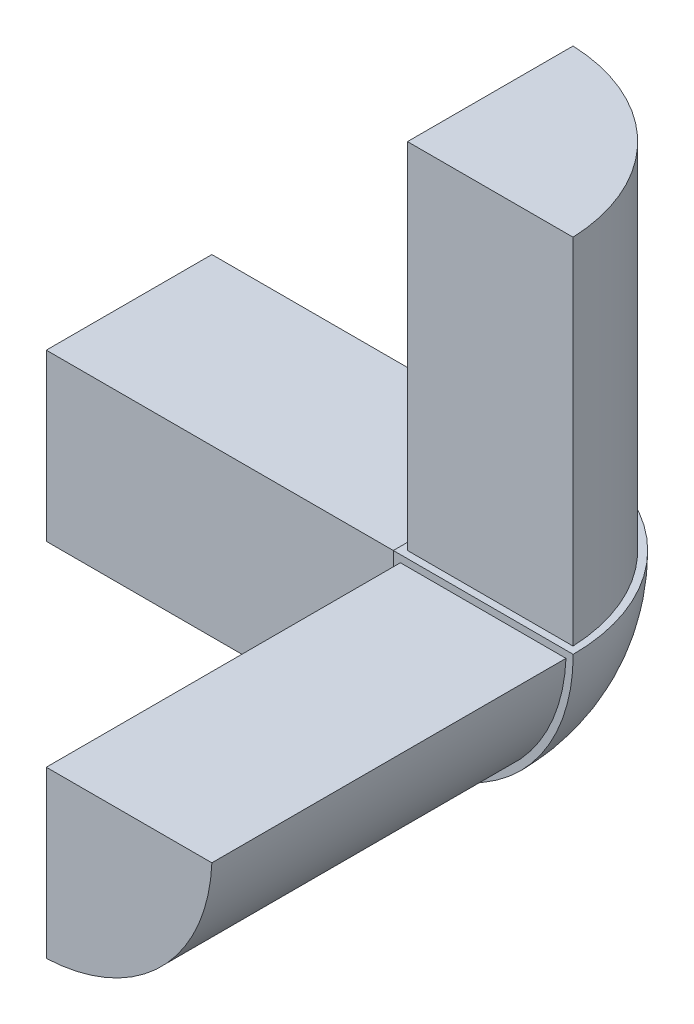
from build123d import *

# Parameters (mm, degrees)
SALIENTE_EXTRUIR1_DEPTH = 50
SALIENTE_EXTRUIR2_DEPTH = 50
SALIENTE_EXTRUIR3_DEPTH = 50
CORTAR_EXTRUIR1_DEPTH   = 30
CROQUIS8_W              = 25.4
CROQUIS8_H              = 25.4
CORTAR_EXTRUIR5_DEPTH   = 50
CROQUIS9_W              = 25.4
CROQUIS9_H              = 25.4
CORTAR_EXTRUIR6_DEPTH   = 50
CORTAR_EXTRUIR7_DEPTH   = 50
CORTAR_EXTRUIR8_DEPTH   = 50
CORTAR_EXTRUIR9_DEPTH   = 50


with BuildPart() as part:
    # Croquis1 → Revolución1 (revolve)
    with BuildSketch(Plane.XY):
        with BuildLine():
            Line((0, 25.4), (0, -25.4))
            ThreePointArc((0, -25.4), (25.4, 0), (0, 25.4))
        make_face()
    revolve(axis=Axis((0, 32.899125747, 0), (0, -1, 0)))

    # Croquis2 → Saliente-Extruir1 (add)
    with BuildSketch(Plane(origin=(0, 0, 0), x_dir=(1, 0, 0), z_dir=(0, 1, 0))):
        with BuildLine():
            Line((0, 25.4), (0, 0))
            Line((0, 0), (25.4, 0))
            ThreePointArc((25.4, 0), (17.960512242, 17.960512242), (0, 25.4))
        make_face()
    extrude(amount=SALIENTE_EXTRUIR1_DEPTH)

    # Croquis3 → Saliente-Extruir2 (add)
    with BuildSketch(Plane.XY):
        with BuildLine():
            Line((0, 0), (25.4, 0))
            ThreePointArc((25.4, 0), (17.960512242, -17.960512242), (0, -25.4))
            Line((0, -25.4), (0, 0))
        make_face()
    extrude(amount=SALIENTE_EXTRUIR2_DEPTH)

    # Croquis4 → Saliente-Extruir3 (add)
    with BuildSketch(Plane(origin=(0, 0, 0), x_dir=(0, 0, -1), z_dir=(1, 0, 0))):
        with BuildLine():
            Line((25.4, 0), (0, 0))
            Line((0, 0), (0, -25.4))
            ThreePointArc((0, -25.4), (17.960512242, -17.960512242), (25.4, 0))
        make_face()
    extrude(amount=-SALIENTE_EXTRUIR3_DEPTH)

    # Croquis5 → Cortar-Extruir1 (cut, symmetric)
    with BuildSketch(Plane.XY):
        with BuildLine():
            Line((0, 25.4), (0, 0))
            Line((0, 0), (-25.4, 0))
            ThreePointArc((-25.4, 0), (-17.960512242, 17.960512242), (0, 25.4))
        make_face()
    extrude(amount=CORTAR_EXTRUIR1_DEPTH, both=True, mode=Mode.SUBTRACT)

    # Croquis8 → Cortar-Extruir5 (cut)
    with BuildSketch(Plane(origin=(0, 0, 0), x_dir=(0, 0, -1), z_dir=(1, 0, 0))):
        with Locations((-12.7, 12.7)):
            Rectangle(CROQUIS8_W, CROQUIS8_H)
    extrude(amount=CORTAR_EXTRUIR5_DEPTH, mode=Mode.SUBTRACT)

    # Croquis9 → Cortar-Extruir6 (cut)
    with BuildSketch(Plane(origin=(0, 0, 0), x_dir=(1, 0, 0), z_dir=(0, 1, 0))):
        with Locations((-12.7, -12.7)):
            Rectangle(CROQUIS9_W, CROQUIS9_H)
    extrude(amount=-CORTAR_EXTRUIR6_DEPTH, mode=Mode.SUBTRACT)

    # Croquis11 → Cortar-Extruir7 (cut)
    with BuildSketch(Plane.ZY.offset(50)):
        with BuildLine():
            Line((0, -25.4), (0, 0))
            Line((0, 0), (-25.4, 0))
            ThreePointArc((-25.4, 0), (-17.960512242, -17.960512242), (0, -25.4))
        make_face()
        with BuildLine():
            Line((-1, -24.379499585), (-1, -1))
            Line((-1, -1), (-24.379499585, -1))
            ThreePointArc((-24.379499585, -1), (-17.253405461, -17.253405461), (-1, -24.379499585))
        make_face(mode=Mode.SUBTRACT)
    extrude(amount=-CORTAR_EXTRUIR7_DEPTH, mode=Mode.SUBTRACT)

    # Croquis12 → Cortar-Extruir8 (cut)
    with BuildSketch(Plane(origin=(0, 50, 0), x_dir=(1, 0, 0), z_dir=(0, 1, 0))):
        with BuildLine():
            Line((0, 25.4), (0, 0))
            Line((0, 0), (25.4, 0))
            ThreePointArc((25.4, 0), (17.960512242, 17.960512242), (0, 25.4))
        make_face()
        with BuildLine():
            Line((1, 24.379499585), (1, 1))
            Line((1, 1), (24.379499585, 1))
            ThreePointArc((24.379499585, 1), (17.253405461, 17.253405461), (1, 24.379499585))
        make_face(mode=Mode.SUBTRACT)
    extrude(amount=-CORTAR_EXTRUIR8_DEPTH, mode=Mode.SUBTRACT)

    # Croquis13 → Cortar-Extruir9 (cut)
    with BuildSketch(Plane.XY.offset(50)):
        with BuildLine():
            Line((0, 0), (0, -25.4))
            ThreePointArc((0, -25.4), (17.960512242, -17.960512242), (25.4, 0))
            Line((25.4, 0), (0, 0))
        make_face()
        with BuildLine():
            Line((1, -1), (1, -24.379499585))
            ThreePointArc((1, -24.379499585), (17.253405461, -17.253405461), (24.379499585, -1))
            Line((24.379499585, -1), (1, -1))
        make_face(mode=Mode.SUBTRACT)
    extrude(amount=-CORTAR_EXTRUIR9_DEPTH, mode=Mode.SUBTRACT)


solid = part.part
